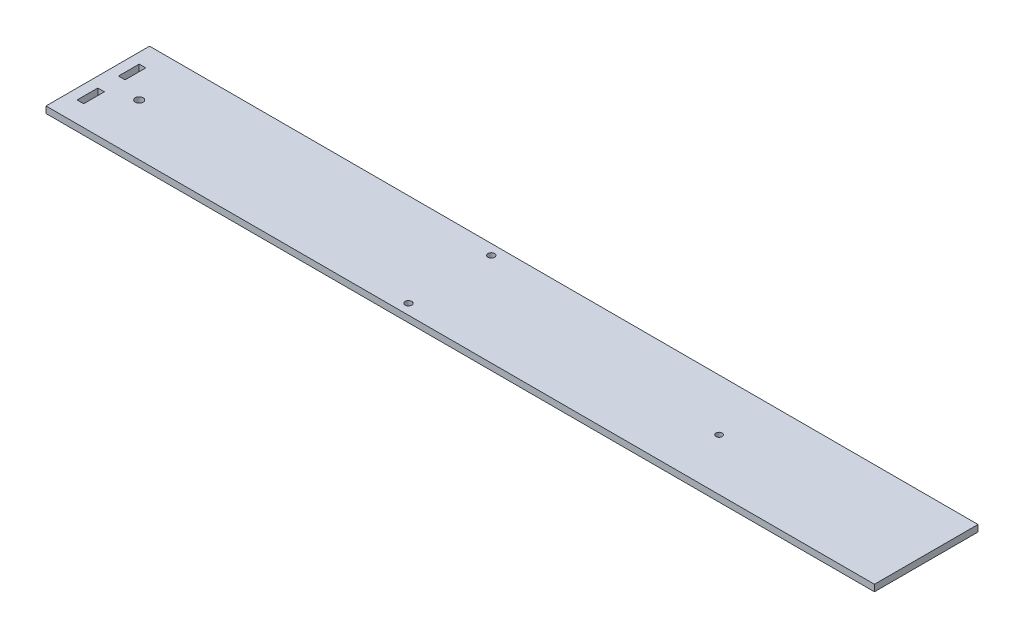
from build123d import *

# Parameters (mm, degrees)
SKETCH1_W           = 400
SKETCH1_H           = 50
SKETCH1_R           = 1.5
SKETCH1_R_2         = 1.6
SKETCH1_R_3         = 1.9
SKETCH1_W_2         = 3.175
SKETCH1_H_2         = 10
BOSS_EXTRUDE1_DEPTH = 3.175


with BuildPart() as part:
    # Sketch1 → Boss-Extrude1 (new body)
    with BuildSketch(Plane(origin=(0, 0, 0), x_dir=(1, 0, 0), z_dir=(0, 1, 0))):
        with Locations((200, 25)):
            Rectangle(SKETCH1_W, SKETCH1_H)
        with Locations((300, 25)):
            Circle(SKETCH1_R, mode=Mode.SUBTRACT)
        with Locations((170, 45)):
            Circle(SKETCH1_R_2, mode=Mode.SUBTRACT)
        with Locations((170, 5)):
            Circle(SKETCH1_R_2, mode=Mode.SUBTRACT)
        with Locations((20, 25)):
            Circle(SKETCH1_R_3, mode=Mode.SUBTRACT)
        with Locations((6.5875, 15)):
            Rectangle(SKETCH1_W_2, SKETCH1_H_2, mode=Mode.SUBTRACT)
        with Locations((6.5875, 35)):
            Rectangle(SKETCH1_W_2, SKETCH1_H_2, mode=Mode.SUBTRACT)
    extrude(amount=BOSS_EXTRUDE1_DEPTH)


solid = part.part
